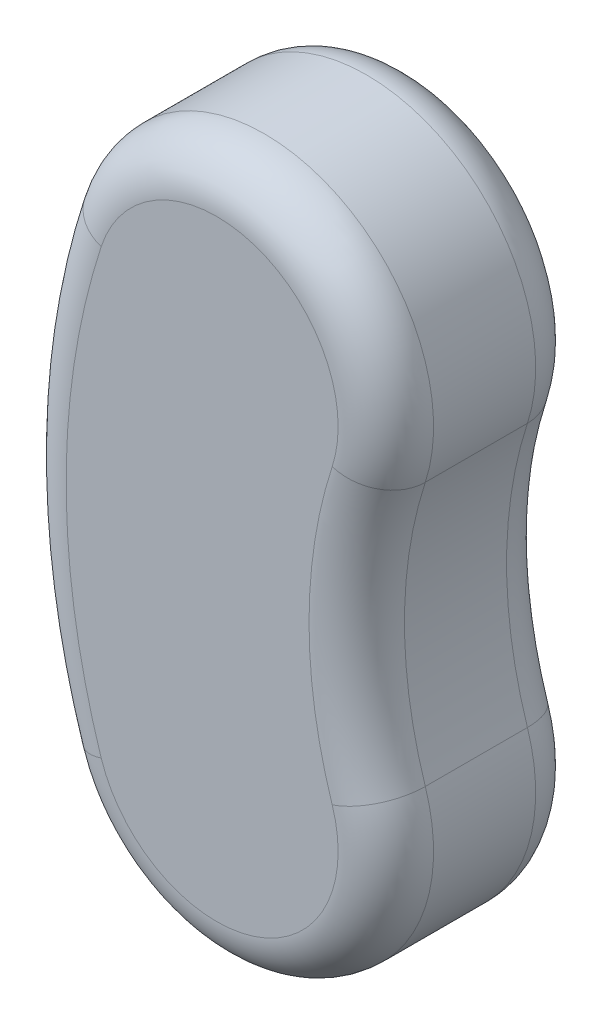
from build123d import *

# Parameters (mm, degrees)
BOSS_EXTRUDE1_DEPTH = 41.4
FILLET1_R           = 10


with BuildPart() as part:
    # Sketch1 → Boss-Extrude1 (new body)
    with BuildSketch(Plane(origin=(0, 0, 0), x_dir=(0, 1, 0), z_dir=(0, 0, 1))):
        with BuildLine():
            ThreePointArc((0, 0), (49.49489115, 7.831876421), (98.9897823, 0))
            ThreePointArc((98.9897823, 0), (121.763014729, -44.663014729), (77.1, -67.436247159))
            ThreePointArc((77.1, -67.436247159), (49.49489115, -63.068123579), (21.8897823, -67.436247159))
            ThreePointArc((21.8897823, -67.436247159), (-22.773232429, -44.663014729), (0, 0))
        make_face()
    extrude(amount=BOSS_EXTRUDE1_DEPTH)

    # Fillet1
    fillet1_edges = [part.edges().sort_by_distance(p)[0] for p in [
        (44.663014729, 121.763014729, 41.4),
        (-7.831876421, 49.49489115, 41.4),
        (44.663014729, -22.773232429, 41.4),
        (-7.831876421, 49.49489115, 0),
        (44.663014729, 121.763014729, 0),
        (63.068123579, 49.49489115, 0),
        (44.663014729, -22.773232429, 0),
        (63.068123579, 49.49489115, 41.4),
    ]]
    fillet(fillet1_edges, radius=FILLET1_R)


solid = part.part
